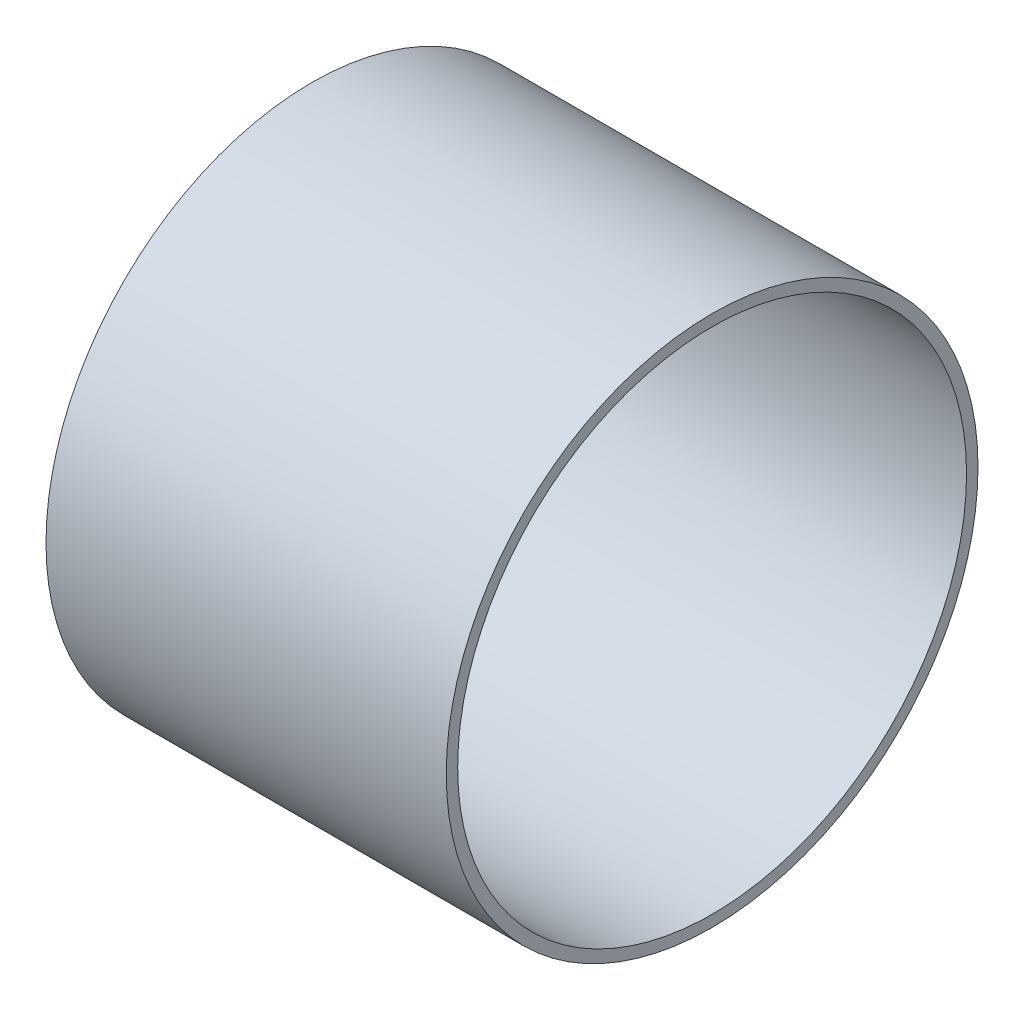
from build123d import *

# Parameters (mm, degrees)
ESQUISSE1_W = 28
ESQUISSE1_H = 0.8


with BuildPart() as part:
    # Esquisse1 → Révolution1 (revolve)
    with BuildSketch(Plane.XY):
        with Locations((0, 18.2)):
            Rectangle(ESQUISSE1_W, ESQUISSE1_H)
    revolve(axis=Axis((-29.925099206, 0, 0), (1, 0, 0)))


solid = part.part
